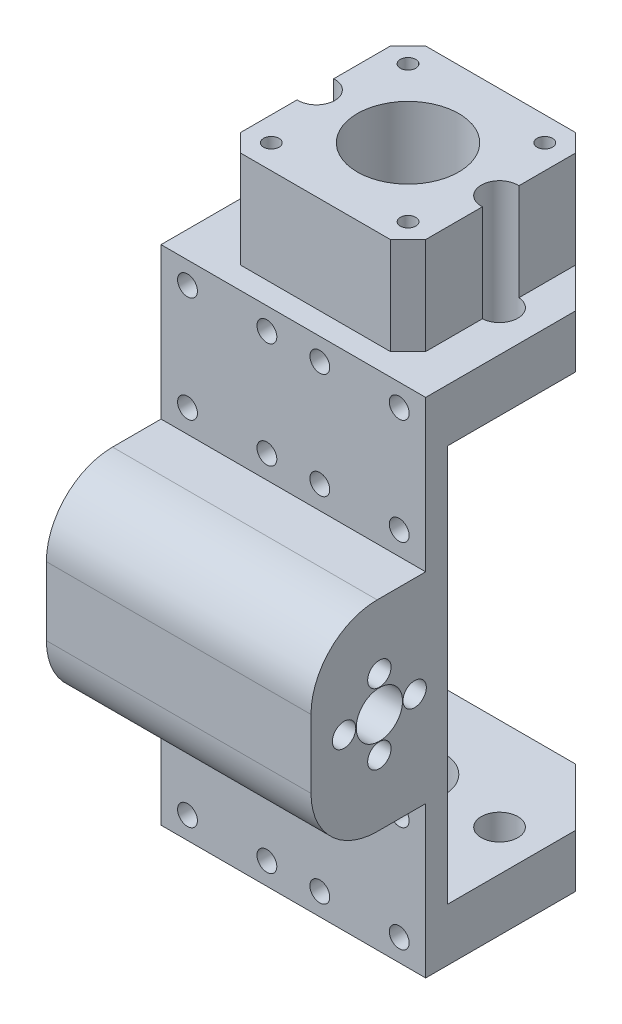
from build123d import *

# Parameters (mm, degrees)
BOSS_EXTRUDE1_DEPTH      = 30
BOSS_EXTRUDE1_DEPTH_BACK = 30
SKETCH2_R                = 5.25
SKETCH3_R                = 11.5
CUT_EXTRUDE2_DEPTH       = 30
CUT_EXTRUDE3_REACH       = 86.198
SKETCH5_R                = 1.75
FILLET1_R                = 15
CUT_EXTRUDE4_REACH       = 73.484
SKETCH6_R                = 2.25
SKETCH7_W                = 60
SKETCH7_H                = 12
BOSS_EXTRUDE2_DEPTH      = 42
SKETCH18_W               = 42
SKETCH18_H               = 42
BOSS_EXTRUDE5_DEPTH      = 22
CUT_EXTRUDE5_REACH       = 155.157
CUT_EXTRUDE5_START       = 22
SKETCH8_R                = 11.5
SKETCH8_R_2              = 1.75
SKETCH8_R_3              = 4.15
SKETCH9_R                = 4.15
SKETCH9_R_2              = 8.15
CUT_EXTRUDE6_DEPTH       = 10
CUT_EXTRUDE7_REACH       = 150.87
SKETCH10_R               = 4.15
SKETCH11_R               = 3
CUT_EXTRUDE8_DEPTH       = 6
SKETCH14_R               = 2.65
CUT_EXTRUDE10_DEPTH      = 5.3
CHAMFER3_SIZE            = 13
CHAMFER4_SIZE            = 4


with BuildPart() as part:
    # Sketch2 → Boss-Extrude1 (new, two sides: drawn at the far end of the back side and taken through both)
    with BuildSketch(Plane(origin=(0, 0, 0), x_dir=(0, 0, -1), z_dir=(1, 0, 0)).offset(-BOSS_EXTRUDE1_DEPTH_BACK)):
        Polygon((15.5, 57), (10.5, 57), (10.5, 22.75), (-15.5, 22.75), (-15.5, -22.75), (10.5, -22.75), (10.5, -57), (15.5, -57), align=None)
        Circle(SKETCH2_R, mode=Mode.SUBTRACT)
    extrude(amount=BOSS_EXTRUDE1_DEPTH + BOSS_EXTRUDE1_DEPTH_BACK)

    # Sketch3 → Cut-Extrude2 (cut)
    with BuildSketch(Plane(origin=(-30, 0, 0), x_dir=(0, 0, -1), z_dir=(1, 0, 0))):
        Circle(SKETCH3_R)
    extrude(amount=CUT_EXTRUDE2_DEPTH, mode=Mode.SUBTRACT)

    # Sketch5 → Cut-Extrude3 (cut, up to next)
    with BuildSketch(Plane(origin=(30, 0, 0), x_dir=(0, 0, -1), z_dir=(1, 0, 0)), mode=Mode.PRIVATE) as cut_extrude3_sk1:
        with Locations((0, 8)):
            Circle(SKETCH5_R)
    cut_extrude3_tool1 = extrude(cut_extrude3_sk1.sketch, amount=-CUT_EXTRUDE3_REACH, mode=Mode.PRIVATE) & part.part
    # Sketch5 → Cut-Extrude3 (cut, up to next)
    with BuildSketch(Plane(origin=(30, 0, 0), x_dir=(0, 0, -1), z_dir=(1, 0, 0)), mode=Mode.PRIVATE) as cut_extrude3_sk2:
        with Locations((8, 0)):
            Circle(SKETCH5_R)
    cut_extrude3_tool2 = extrude(cut_extrude3_sk2.sketch, amount=-CUT_EXTRUDE3_REACH, mode=Mode.PRIVATE) & part.part
    # Sketch5 → Cut-Extrude3 (cut, up to next)
    with BuildSketch(Plane(origin=(30, 0, 0), x_dir=(0, 0, -1), z_dir=(1, 0, 0)), mode=Mode.PRIVATE) as cut_extrude3_sk3:
        with Locations((0, -8)):
            Circle(SKETCH5_R)
    cut_extrude3_tool3 = extrude(cut_extrude3_sk3.sketch, amount=-CUT_EXTRUDE3_REACH, mode=Mode.PRIVATE) & part.part
    # Sketch5 → Cut-Extrude3 (cut, up to next)
    with BuildSketch(Plane(origin=(30, 0, 0), x_dir=(0, 0, -1), z_dir=(1, 0, 0)), mode=Mode.PRIVATE) as cut_extrude3_sk4:
        with Locations((-8, 0)):
            Circle(SKETCH5_R)
    cut_extrude3_tool4 = extrude(cut_extrude3_sk4.sketch, amount=-CUT_EXTRUDE3_REACH, mode=Mode.PRIVATE) & part.part
    add(cut_extrude3_tool1.solids().sort_by_distance((30, 8, 0))[0], mode=Mode.SUBTRACT)
    add(cut_extrude3_tool2.solids().sort_by_distance((30, 0, -8))[0], mode=Mode.SUBTRACT)
    add(cut_extrude3_tool3.solids().sort_by_distance((30, -8, 0))[0], mode=Mode.SUBTRACT)
    add(cut_extrude3_tool4.solids().sort_by_distance((30, 0, 8))[0], mode=Mode.SUBTRACT)

    # Fillet1
    fillet1_edges = [part.edges().sort_by_distance(p)[0] for p in [
        (0, -22.75, 15.5),
        (0, 22.75, 15.5),
    ]]
    fillet(fillet1_edges, radius=FILLET1_R)

    # Sketch6 → Cut-Extrude4 (cut, up to next)
    with BuildSketch(Plane(origin=(0, 0, -15.5), x_dir=(-1, 0, 0), z_dir=(0, 0, -1)), mode=Mode.PRIVATE) as cut_extrude4_sk1:
        with Locations((-24, 52)):
            Circle(SKETCH6_R)
    cut_extrude4_tool1 = extrude(cut_extrude4_sk1.sketch, amount=-CUT_EXTRUDE4_REACH, mode=Mode.PRIVATE) & part.part
    # Sketch6 → Cut-Extrude4 (cut, up to next)
    with BuildSketch(Plane(origin=(0, 0, -15.5), x_dir=(-1, 0, 0), z_dir=(0, 0, -1)), mode=Mode.PRIVATE) as cut_extrude4_sk2:
        with Locations((-6, 52)):
            Circle(SKETCH6_R)
    cut_extrude4_tool2 = extrude(cut_extrude4_sk2.sketch, amount=-CUT_EXTRUDE4_REACH, mode=Mode.PRIVATE) & part.part
    # Sketch6 → Cut-Extrude4 (cut, up to next)
    with BuildSketch(Plane(origin=(0, 0, -15.5), x_dir=(-1, 0, 0), z_dir=(0, 0, -1)), mode=Mode.PRIVATE) as cut_extrude4_sk3:
        with Locations((-24, 28)):
            Circle(SKETCH6_R)
    cut_extrude4_tool3 = extrude(cut_extrude4_sk3.sketch, amount=-CUT_EXTRUDE4_REACH, mode=Mode.PRIVATE) & part.part
    # Sketch6 → Cut-Extrude4 (cut, up to next)
    with BuildSketch(Plane(origin=(0, 0, -15.5), x_dir=(-1, 0, 0), z_dir=(0, 0, -1)), mode=Mode.PRIVATE) as cut_extrude4_sk4:
        with Locations((-6, 28)):
            Circle(SKETCH6_R)
    cut_extrude4_tool4 = extrude(cut_extrude4_sk4.sketch, amount=-CUT_EXTRUDE4_REACH, mode=Mode.PRIVATE) & part.part
    # Sketch6 → Cut-Extrude4 (cut, up to next)
    with BuildSketch(Plane(origin=(0, 0, -15.5), x_dir=(-1, 0, 0), z_dir=(0, 0, -1)), mode=Mode.PRIVATE) as cut_extrude4_sk5:
        with Locations((6, 28)):
            Circle(SKETCH6_R)
    cut_extrude4_tool5 = extrude(cut_extrude4_sk5.sketch, amount=-CUT_EXTRUDE4_REACH, mode=Mode.PRIVATE) & part.part
    # Sketch6 → Cut-Extrude4 (cut, up to next)
    with BuildSketch(Plane(origin=(0, 0, -15.5), x_dir=(-1, 0, 0), z_dir=(0, 0, -1)), mode=Mode.PRIVATE) as cut_extrude4_sk6:
        with Locations((24, 28)):
            Circle(SKETCH6_R)
    cut_extrude4_tool6 = extrude(cut_extrude4_sk6.sketch, amount=-CUT_EXTRUDE4_REACH, mode=Mode.PRIVATE) & part.part
    # Sketch6 → Cut-Extrude4 (cut, up to next)
    with BuildSketch(Plane(origin=(0, 0, -15.5), x_dir=(-1, 0, 0), z_dir=(0, 0, -1)), mode=Mode.PRIVATE) as cut_extrude4_sk7:
        with Locations((6, 52)):
            Circle(SKETCH6_R)
    cut_extrude4_tool7 = extrude(cut_extrude4_sk7.sketch, amount=-CUT_EXTRUDE4_REACH, mode=Mode.PRIVATE) & part.part
    # Sketch6 → Cut-Extrude4 (cut, up to next)
    with BuildSketch(Plane(origin=(0, 0, -15.5), x_dir=(-1, 0, 0), z_dir=(0, 0, -1)), mode=Mode.PRIVATE) as cut_extrude4_sk8:
        with Locations((24, 52)):
            Circle(SKETCH6_R)
    cut_extrude4_tool8 = extrude(cut_extrude4_sk8.sketch, amount=-CUT_EXTRUDE4_REACH, mode=Mode.PRIVATE) & part.part
    # Sketch6 → Cut-Extrude4 (cut, up to next)
    with BuildSketch(Plane(origin=(0, 0, -15.5), x_dir=(-1, 0, 0), z_dir=(0, 0, -1)), mode=Mode.PRIVATE) as cut_extrude4_sk9:
        with Locations((24, -52)):
            Circle(SKETCH6_R)
    cut_extrude4_tool9 = extrude(cut_extrude4_sk9.sketch, amount=-CUT_EXTRUDE4_REACH, mode=Mode.PRIVATE) & part.part
    # Sketch6 → Cut-Extrude4 (cut, up to next)
    with BuildSketch(Plane(origin=(0, 0, -15.5), x_dir=(-1, 0, 0), z_dir=(0, 0, -1)), mode=Mode.PRIVATE) as cut_extrude4_sk10:
        with Locations((6, -52)):
            Circle(SKETCH6_R)
    cut_extrude4_tool10 = extrude(cut_extrude4_sk10.sketch, amount=-CUT_EXTRUDE4_REACH, mode=Mode.PRIVATE) & part.part
    # Sketch6 → Cut-Extrude4 (cut, up to next)
    with BuildSketch(Plane(origin=(0, 0, -15.5), x_dir=(-1, 0, 0), z_dir=(0, 0, -1)), mode=Mode.PRIVATE) as cut_extrude4_sk11:
        with Locations((24, -28)):
            Circle(SKETCH6_R)
    cut_extrude4_tool11 = extrude(cut_extrude4_sk11.sketch, amount=-CUT_EXTRUDE4_REACH, mode=Mode.PRIVATE) & part.part
    # Sketch6 → Cut-Extrude4 (cut, up to next)
    with BuildSketch(Plane(origin=(0, 0, -15.5), x_dir=(-1, 0, 0), z_dir=(0, 0, -1)), mode=Mode.PRIVATE) as cut_extrude4_sk12:
        with Locations((6, -28)):
            Circle(SKETCH6_R)
    cut_extrude4_tool12 = extrude(cut_extrude4_sk12.sketch, amount=-CUT_EXTRUDE4_REACH, mode=Mode.PRIVATE) & part.part
    # Sketch6 → Cut-Extrude4 (cut, up to next)
    with BuildSketch(Plane(origin=(0, 0, -15.5), x_dir=(-1, 0, 0), z_dir=(0, 0, -1)), mode=Mode.PRIVATE) as cut_extrude4_sk13:
        with Locations((-6, -28)):
            Circle(SKETCH6_R)
    cut_extrude4_tool13 = extrude(cut_extrude4_sk13.sketch, amount=-CUT_EXTRUDE4_REACH, mode=Mode.PRIVATE) & part.part
    # Sketch6 → Cut-Extrude4 (cut, up to next)
    with BuildSketch(Plane(origin=(0, 0, -15.5), x_dir=(-1, 0, 0), z_dir=(0, 0, -1)), mode=Mode.PRIVATE) as cut_extrude4_sk14:
        with Locations((-24, -28)):
            Circle(SKETCH6_R)
    cut_extrude4_tool14 = extrude(cut_extrude4_sk14.sketch, amount=-CUT_EXTRUDE4_REACH, mode=Mode.PRIVATE) & part.part
    # Sketch6 → Cut-Extrude4 (cut, up to next)
    with BuildSketch(Plane(origin=(0, 0, -15.5), x_dir=(-1, 0, 0), z_dir=(0, 0, -1)), mode=Mode.PRIVATE) as cut_extrude4_sk15:
        with Locations((-6, -52)):
            Circle(SKETCH6_R)
    cut_extrude4_tool15 = extrude(cut_extrude4_sk15.sketch, amount=-CUT_EXTRUDE4_REACH, mode=Mode.PRIVATE) & part.part
    # Sketch6 → Cut-Extrude4 (cut, up to next)
    with BuildSketch(Plane(origin=(0, 0, -15.5), x_dir=(-1, 0, 0), z_dir=(0, 0, -1)), mode=Mode.PRIVATE) as cut_extrude4_sk16:
        with Locations((-24, -52)):
            Circle(SKETCH6_R)
    cut_extrude4_tool16 = extrude(cut_extrude4_sk16.sketch, amount=-CUT_EXTRUDE4_REACH, mode=Mode.PRIVATE) & part.part
    add(cut_extrude4_tool1.solids().sort_by_distance((24, 52, -15.5))[0], mode=Mode.SUBTRACT)
    add(cut_extrude4_tool2.solids().sort_by_distance((6, 52, -15.5))[0], mode=Mode.SUBTRACT)
    add(cut_extrude4_tool3.solids().sort_by_distance((24, 28, -15.5))[0], mode=Mode.SUBTRACT)
    add(cut_extrude4_tool4.solids().sort_by_distance((6, 28, -15.5))[0], mode=Mode.SUBTRACT)
    add(cut_extrude4_tool5.solids().sort_by_distance((-6, 28, -15.5))[0], mode=Mode.SUBTRACT)
    add(cut_extrude4_tool6.solids().sort_by_distance((-24, 28, -15.5))[0], mode=Mode.SUBTRACT)
    add(cut_extrude4_tool7.solids().sort_by_distance((-6, 52, -15.5))[0], mode=Mode.SUBTRACT)
    add(cut_extrude4_tool8.solids().sort_by_distance((-24, 52, -15.5))[0], mode=Mode.SUBTRACT)
    add(cut_extrude4_tool9.solids().sort_by_distance((-24, -52, -15.5))[0], mode=Mode.SUBTRACT)
    add(cut_extrude4_tool10.solids().sort_by_distance((-6, -52, -15.5))[0], mode=Mode.SUBTRACT)
    add(cut_extrude4_tool11.solids().sort_by_distance((-24, -28, -15.5))[0], mode=Mode.SUBTRACT)
    add(cut_extrude4_tool12.solids().sort_by_distance((-6, -28, -15.5))[0], mode=Mode.SUBTRACT)
    add(cut_extrude4_tool13.solids().sort_by_distance((6, -28, -15.5))[0], mode=Mode.SUBTRACT)
    add(cut_extrude4_tool14.solids().sort_by_distance((24, -28, -15.5))[0], mode=Mode.SUBTRACT)
    add(cut_extrude4_tool15.solids().sort_by_distance((6, -52, -15.5))[0], mode=Mode.SUBTRACT)
    add(cut_extrude4_tool16.solids().sort_by_distance((24, -52, -15.5))[0], mode=Mode.SUBTRACT)

    # Sketch7 → Boss-Extrude2 (add)
    with BuildSketch(Plane(origin=(0, 0, -15.5), x_dir=(-1, 0, 0), z_dir=(0, 0, -1))):
        with Locations((0, 51)):
            Rectangle(SKETCH7_W, SKETCH7_H)
        with Locations((0, -51)):
            Rectangle(SKETCH7_W, SKETCH7_H)
    extrude(amount=BOSS_EXTRUDE2_DEPTH)

    # Sketch18 → Boss-Extrude5 (add)
    with BuildSketch(Plane(origin=(0, 57, 0), x_dir=(1, 0, 0), z_dir=(0, 1, 0))):
        with Locations((0, 36.5)):
            Rectangle(SKETCH18_W, SKETCH18_H)
    extrude(amount=BOSS_EXTRUDE5_DEPTH)

    # Sketch8 → Cut-Extrude5 (cut, up to next)
    with BuildSketch(Plane(origin=(0, 57, 0), x_dir=(1, 0, 0), z_dir=(0, 1, 0)).offset(CUT_EXTRUDE5_START), mode=Mode.PRIVATE) as cut_extrude5_sk1:
        with Locations((0, 36.5)):
            Circle(SKETCH8_R)
    cut_extrude5_tool1 = extrude(cut_extrude5_sk1.sketch, amount=-CUT_EXTRUDE5_REACH, mode=Mode.PRIVATE) & part.part
    # Sketch8 → Cut-Extrude5 (cut, up to next)
    with BuildSketch(Plane(origin=(0, 57, 0), x_dir=(1, 0, 0), z_dir=(0, 1, 0)).offset(CUT_EXTRUDE5_START), mode=Mode.PRIVATE) as cut_extrude5_sk2:
        with Locations((-15.5, 52)):
            Circle(SKETCH8_R_2)
    cut_extrude5_tool2 = extrude(cut_extrude5_sk2.sketch, amount=-CUT_EXTRUDE5_REACH, mode=Mode.PRIVATE) & part.part
    # Sketch8 → Cut-Extrude5 (cut, up to next)
    with BuildSketch(Plane(origin=(0, 57, 0), x_dir=(1, 0, 0), z_dir=(0, 1, 0)).offset(CUT_EXTRUDE5_START), mode=Mode.PRIVATE) as cut_extrude5_sk3:
        with Locations((15.5, 52)):
            Circle(SKETCH8_R_2)
    cut_extrude5_tool3 = extrude(cut_extrude5_sk3.sketch, amount=-CUT_EXTRUDE5_REACH, mode=Mode.PRIVATE) & part.part
    # Sketch8 → Cut-Extrude5 (cut, up to next)
    with BuildSketch(Plane(origin=(0, 57, 0), x_dir=(1, 0, 0), z_dir=(0, 1, 0)).offset(CUT_EXTRUDE5_START), mode=Mode.PRIVATE) as cut_extrude5_sk4:
        with Locations((15.5, 21)):
            Circle(SKETCH8_R_2)
    cut_extrude5_tool4 = extrude(cut_extrude5_sk4.sketch, amount=-CUT_EXTRUDE5_REACH, mode=Mode.PRIVATE) & part.part
    # Sketch8 → Cut-Extrude5 (cut, up to next)
    with BuildSketch(Plane(origin=(0, 57, 0), x_dir=(1, 0, 0), z_dir=(0, 1, 0)).offset(CUT_EXTRUDE5_START), mode=Mode.PRIVATE) as cut_extrude5_sk5:
        with Locations((-15.5, 21)):
            Circle(SKETCH8_R_2)
    cut_extrude5_tool5 = extrude(cut_extrude5_sk5.sketch, amount=-CUT_EXTRUDE5_REACH, mode=Mode.PRIVATE) & part.part
    # Sketch8 → Cut-Extrude5 (cut, up to next)
    with BuildSketch(Plane(origin=(0, 57, 0), x_dir=(1, 0, 0), z_dir=(0, 1, 0)).offset(CUT_EXTRUDE5_START), mode=Mode.PRIVATE) as cut_extrude5_sk6:
        with Locations((-20.75, 36.5)):
            Circle(SKETCH8_R_3)
    cut_extrude5_tool6 = extrude(cut_extrude5_sk6.sketch, amount=-CUT_EXTRUDE5_REACH, mode=Mode.PRIVATE) & part.part
    # Sketch8 → Cut-Extrude5 (cut, up to next)
    with BuildSketch(Plane(origin=(0, 57, 0), x_dir=(1, 0, 0), z_dir=(0, 1, 0)).offset(CUT_EXTRUDE5_START), mode=Mode.PRIVATE) as cut_extrude5_sk7:
        with Locations((20.75, 36.5)):
            Circle(SKETCH8_R_3)
    cut_extrude5_tool7 = extrude(cut_extrude5_sk7.sketch, amount=-CUT_EXTRUDE5_REACH, mode=Mode.PRIVATE) & part.part
    add(cut_extrude5_tool1.solids().sort_by_distance((0, 79, -36.5))[0], mode=Mode.SUBTRACT)
    add(cut_extrude5_tool2.solids().sort_by_distance((-15.5, 79, -52))[0], mode=Mode.SUBTRACT)
    add(cut_extrude5_tool3.solids().sort_by_distance((15.5, 79, -52))[0], mode=Mode.SUBTRACT)
    add(cut_extrude5_tool4.solids().sort_by_distance((15.5, 79, -21))[0], mode=Mode.SUBTRACT)
    add(cut_extrude5_tool5.solids().sort_by_distance((-15.5, 79, -21))[0], mode=Mode.SUBTRACT)
    add(cut_extrude5_tool6.solids().sort_by_distance((-20.75, 79, -36.5))[0], mode=Mode.SUBTRACT)
    add(cut_extrude5_tool7.solids().sort_by_distance((20.75, 79, -36.5))[0], mode=Mode.SUBTRACT)

    # Sketch9 → Cut-Extrude6 (cut)
    with BuildSketch(Plane(origin=(0, -45, 0), x_dir=(1, 0, 0), z_dir=(0, 1, 0))):
        with Locations((-20.75, 36.5)):
            Circle(SKETCH9_R)
        with Locations((20.75, 36.5)):
            Circle(SKETCH9_R)
        with Locations((0, 36.5)):
            Circle(SKETCH9_R_2)
    extrude(amount=-CUT_EXTRUDE6_DEPTH, mode=Mode.SUBTRACT)

    # Sketch10 → Cut-Extrude7 (cut, up to next)
    with BuildSketch(Plane(origin=(0, -55, 0), x_dir=(1, 0, 0), z_dir=(0, 1, 0)), mode=Mode.PRIVATE) as cut_extrude7_sk1:
        with Locations((0, 36.5)):
            Circle(SKETCH10_R)
    cut_extrude7_tool1 = extrude(cut_extrude7_sk1.sketch, amount=-CUT_EXTRUDE7_REACH, mode=Mode.PRIVATE) & part.part
    add(cut_extrude7_tool1.solids().sort_by_distance((0, -55, -36.5))[0], mode=Mode.SUBTRACT)

    # Sketch11 → Cut-Extrude8 (cut)
    with BuildSketch(Plane.XZ.offset(-45)):
        with Locations((15.5, -52)):
            Circle(SKETCH11_R)
        with Locations((-15.5, -52)):
            Circle(SKETCH11_R)
        with Locations((-15.5, -21)):
            Circle(SKETCH11_R)
        with Locations((15.5, -21)):
            Circle(SKETCH11_R)
    extrude(amount=-CUT_EXTRUDE8_DEPTH, mode=Mode.SUBTRACT)

    # Sketch14 → Cut-Extrude10 (cut)
    with BuildSketch(Plane(origin=(30, 0, 0), x_dir=(0, 0, -1), z_dir=(1, 0, 0))):
        with Locations((0, 8)):
            Circle(SKETCH14_R)
        with Locations((8, 0)):
            Circle(SKETCH14_R)
        with Locations((0, -8)):
            Circle(SKETCH14_R)
        with Locations((-8, 0)):
            Circle(SKETCH14_R)
    extrude(amount=-CUT_EXTRUDE10_DEPTH, mode=Mode.SUBTRACT)

    # Chamfer3
    chamfer3_edges = [part.edges().sort_by_distance(p)[0] for p in [
        (30, 51, -57.5),
        (-30, 51, -57.5),
        (-30, -51, -57.5),
        (30, -51, -57.5),
    ]]
    chamfer(chamfer3_edges, length=CHAMFER3_SIZE)

    # Chamfer4
    chamfer4_edges = [part.edges().sort_by_distance(p)[0] for p in [
        (21, 68, -15.5),
        (-21, 68, -15.5),
    ]]
    chamfer(chamfer4_edges, length=CHAMFER4_SIZE)


solid = part.part
